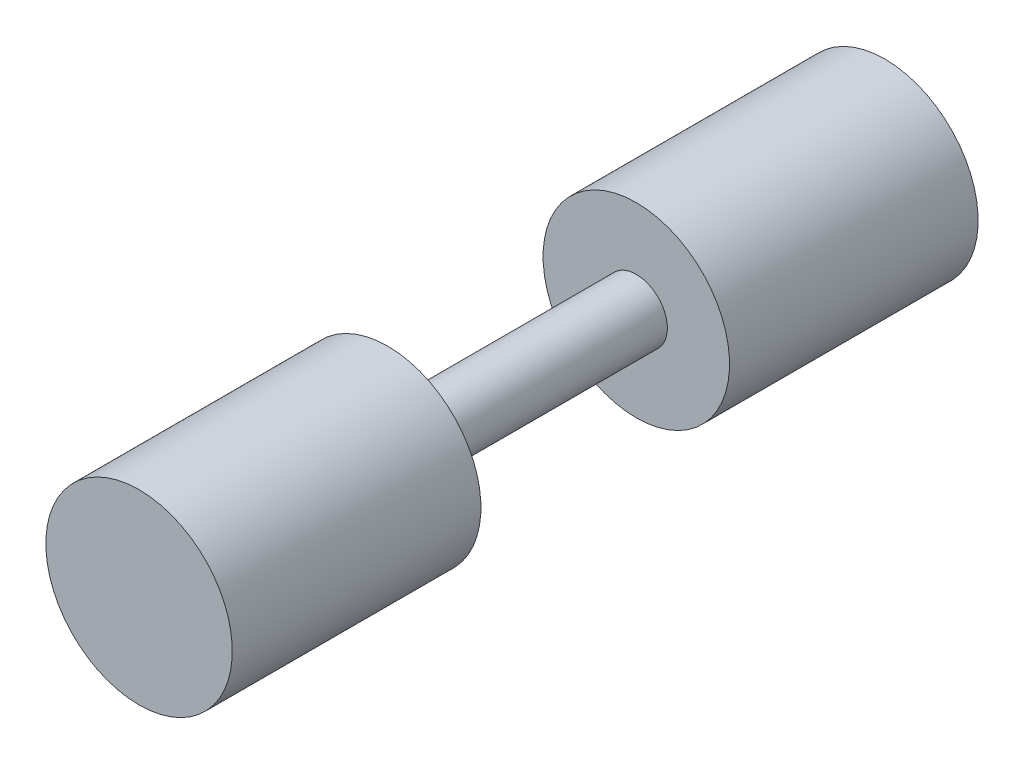
from build123d import *


with BuildPart() as part:
    # Sketch1 → Revolve1 (revolve)
    with BuildSketch(Plane(origin=(0, 0, 0), x_dir=(0, 0, -1), z_dir=(1, 0, 0))):
        Polygon((76.2, 0), (-76.2, 0), (-76.2, 19.05), (-25.4, 19.05), (-25.4, 6.35), (25.4, 6.35), (25.4, 19.05), (76.2, 19.05), align=None)
    revolve(axis=Axis((0, 0, -76.2), (0, 0, 1)))


solid = part.part
